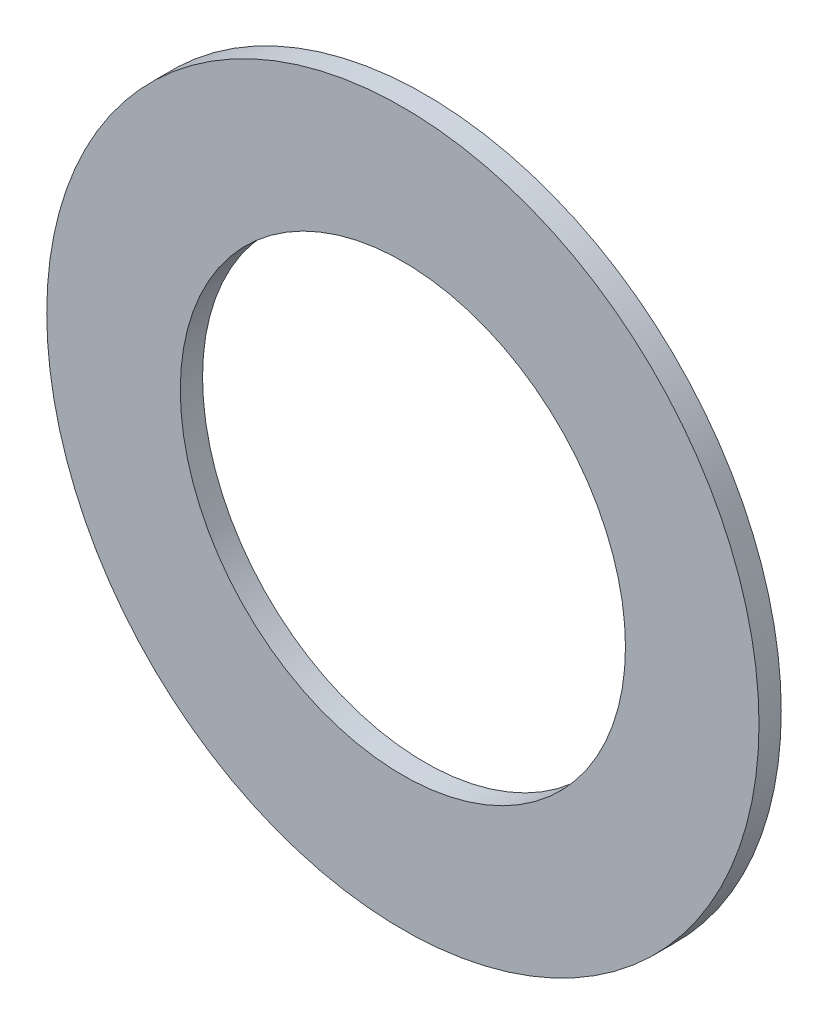
from build123d import *

# Parameters (mm, degrees)
SKETCH1_R           = 8
SKETCH1_R_2         = 5
BOSS_EXTRUDE1_DEPTH = 0.5


with BuildPart() as part:
    # Sketch1 → Boss-Extrude1 (new body)
    with BuildSketch(Plane.XY):
        Circle(SKETCH1_R)
        Circle(SKETCH1_R_2, mode=Mode.SUBTRACT)
    extrude(amount=BOSS_EXTRUDE1_DEPTH)


solid = part.part
